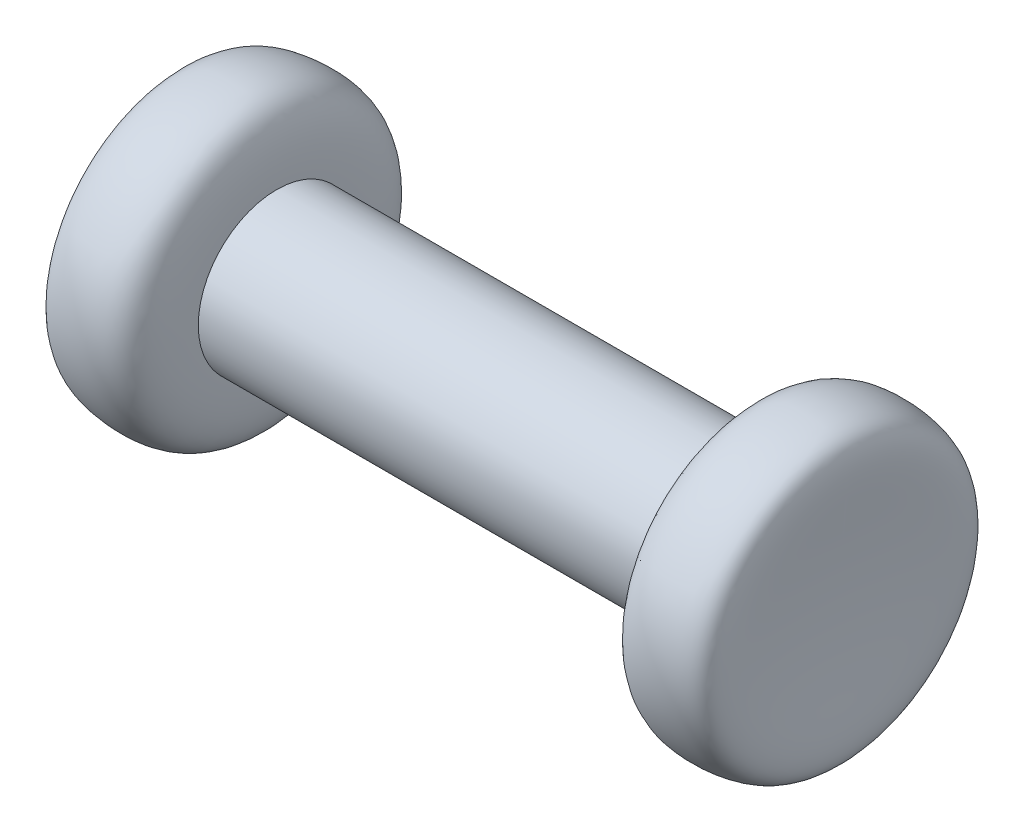
from build123d import *


with BuildPart() as part:
    # Sketch1 → Revolve1 (revolve)
    with BuildSketch(Plane.XY):
        with BuildLine():
            Line((-7.5, 0), (7.5, 0))
            add(Edge.make_bspline(
                [(7.5, 0), (7.5, 1.212584137), (7.732749838, 2.333425204), (11.391717028, 2.19039985), (10.5, 1.133564637), (10.5, -2.5)],
                knots=[0, 0, 0, 0, 0.265537356, 0.444563775, 1, 1, 1, 1], degree=3))
            Line((10.5, -2.5), (-10.5, -2.5))
            add(Edge.make_bspline(
                [(-7.5, 0), (-7.5, 1.212584137), (-7.732749838, 2.333425204), (-11.391717028, 2.19039985), (-10.5, 1.133564637), (-10.5, -2.5)],
                knots=[0, 0, 0, 0, 0.265537356, 0.444563775, 1, 1, 1, 1], degree=3))
        make_face()
    revolve(axis=Axis((-10.5, -2.5, 0), (1, 0, 0)))


solid = part.part
